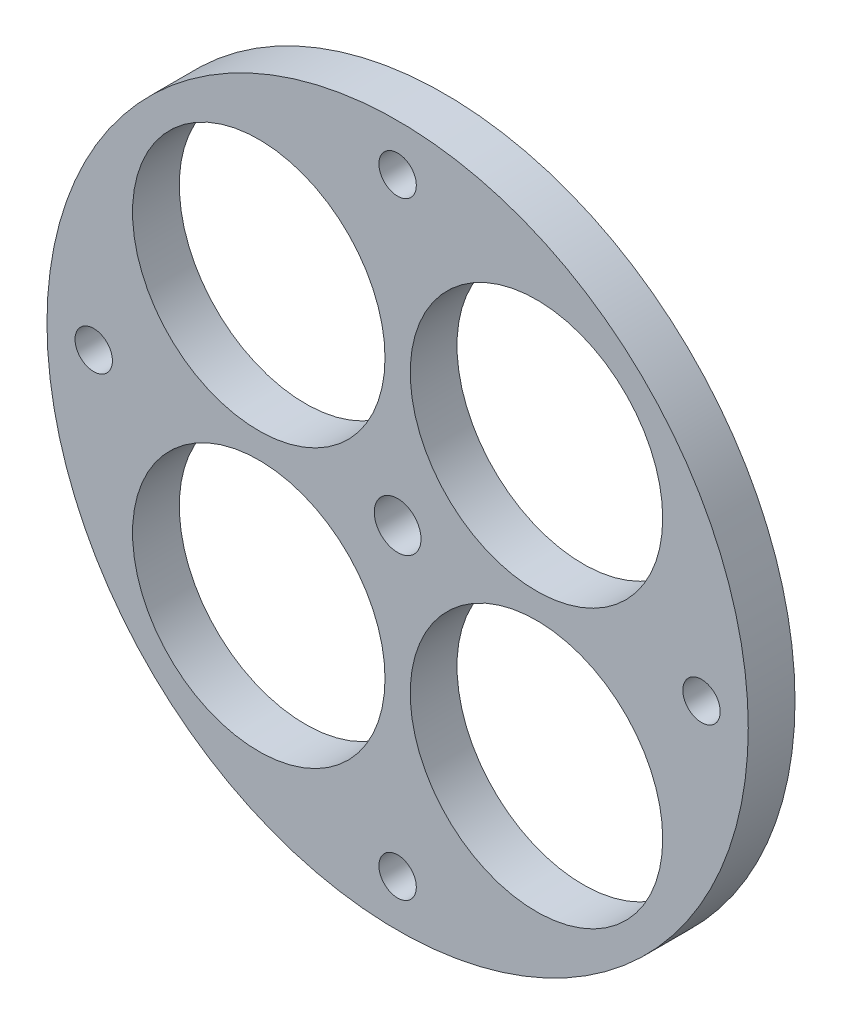
from build123d import *

# Parameters (mm, degrees)
SKETCH1_R           = 75
SKETCH1_R_2         = 27
SKETCH1_R_3         = 5
SKETCH1_R_4         = 4
BOSS_EXTRUDE1_DEPTH = 10


with BuildPart() as part:
    # Sketch1 → Boss-Extrude1 (new body)
    with BuildSketch(Plane.XY):
        Circle(SKETCH1_R)
        with Locations((-29.69848481, 29.69848481)):
            Circle(SKETCH1_R_2, mode=Mode.SUBTRACT)
        with Locations((29.69848481, 29.69848481)):
            Circle(SKETCH1_R_2, mode=Mode.SUBTRACT)
        with Locations((29.69848481, -29.69848481)):
            Circle(SKETCH1_R_2, mode=Mode.SUBTRACT)
        with Locations((-29.69848481, -29.69848481)):
            Circle(SKETCH1_R_2, mode=Mode.SUBTRACT)
        Circle(SKETCH1_R_3, mode=Mode.SUBTRACT)
        with Locations((0, 65)):
            Circle(SKETCH1_R_4, mode=Mode.SUBTRACT)
        with Locations((65, 0)):
            Circle(SKETCH1_R_4, mode=Mode.SUBTRACT)
        with Locations((0, -65)):
            Circle(SKETCH1_R_4, mode=Mode.SUBTRACT)
        with Locations((-65, 0)):
            Circle(SKETCH1_R_4, mode=Mode.SUBTRACT)
    extrude(amount=BOSS_EXTRUDE1_DEPTH)


solid = part.part
